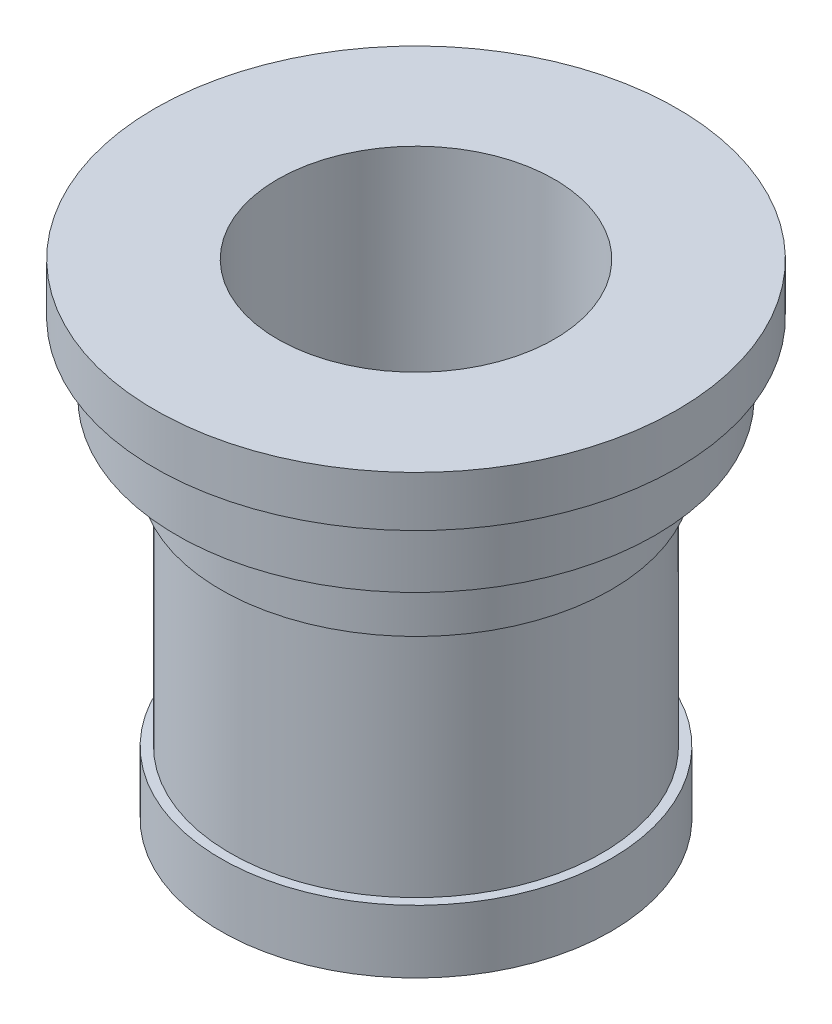
from build123d import *

# Parameters (mm, degrees)
SKETCH2_R          = 1.5
CUT_EXTRUDE1_DEPTH = 5


with BuildPart() as part:
    # Sketch1 → Revolve1 (revolve)
    with BuildSketch(Plane.XY):
        Polygon((9, 0), (0, 0), (0, 10), (1.5, 10), (1.5, 47), (0, 47), (0, 58), (-7, 58), (-7, 69), (-10.5, 69), (-10.5, 77), (9, 77), align=None)
    revolve(axis=Axis((31, 85.626822198, 0), (0, -1, 0)))

    # Sketch2 → Cut-Extrude1 (cut)
    with BuildSketch(Plane.XZ):
        with Locations((9, 0)):
            Circle(SKETCH2_R)
    extrude(amount=-CUT_EXTRUDE1_DEPTH, mode=Mode.SUBTRACT)


solid = part.part
